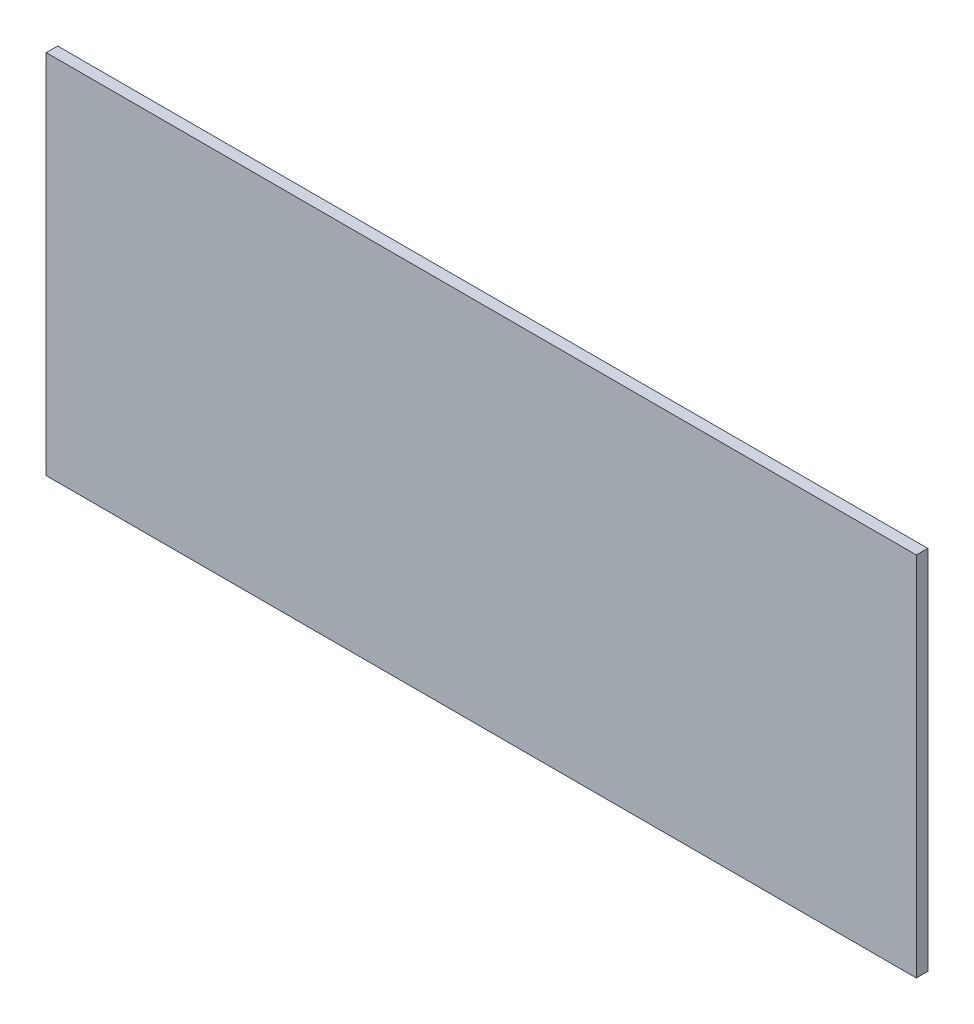
from build123d import *

# Parameters (mm, degrees)
SKETCH1_W           = 120.65
SKETCH1_H           = 50.8
BOSS_EXTRUDE1_DEPTH = 1.5875


with BuildPart() as part:
    # Sketch1 → Boss-Extrude1 (new body)
    with BuildSketch(Plane.XY):
        with Locations((60.325, 25.4)):
            Rectangle(SKETCH1_W, SKETCH1_H)
    extrude(amount=BOSS_EXTRUDE1_DEPTH)


solid = part.part
